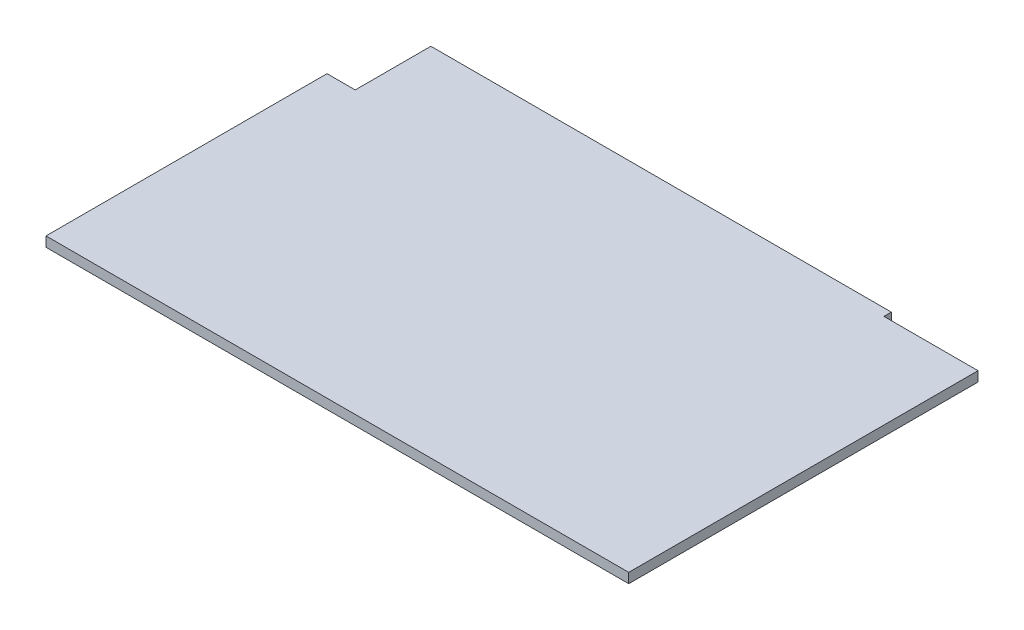
from build123d import *

# Parameters (mm, degrees)
BOSS_EXTRUDE1_DEPTH = 2.67


with BuildPart() as part:
    # Sketch1 → Boss-Extrude1 (new body)
    with BuildSketch(Plane(origin=(0, 0, 0), x_dir=(1, 0, 0), z_dir=(0, 1, 0))):
        Polygon((0, 0), (0, 75.95), (7.62, 75.95), (7.62, 96.4), (132.07, 96.4), (132.07, 94.4), (157.49, 94.4), (157.49, 0), align=None)
    extrude(amount=BOSS_EXTRUDE1_DEPTH)


solid = part.part
